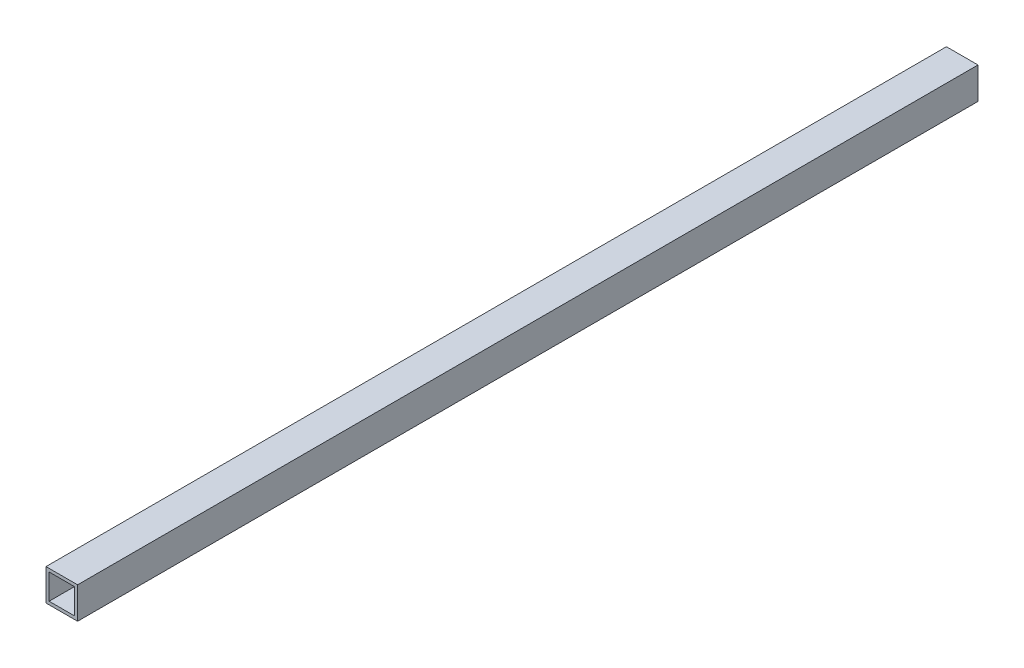
from build123d import *

# Parameters (mm, degrees)
SKETCH1_W           = 20
SKETCH1_H           = 20
SKETCH1_W_2         = 16.042271314
SKETCH1_H_2         = 16.042271314
BOSS_EXTRUDE1_DEPTH = 570


with BuildPart() as part:
    # Sketch1 → Boss-Extrude1 (new body)
    with BuildSketch(Plane.XY):
        Rectangle(SKETCH1_W, SKETCH1_H)
        Rectangle(SKETCH1_W_2, SKETCH1_H_2, mode=Mode.SUBTRACT)
    extrude(amount=BOSS_EXTRUDE1_DEPTH)


solid = part.part
